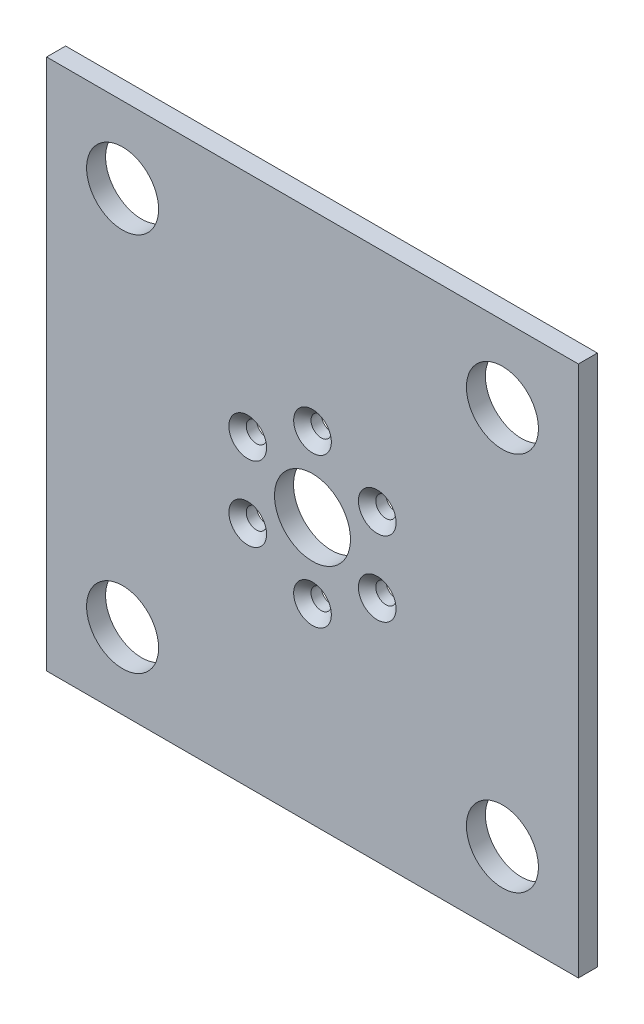
from build123d import *

# Parameters (mm, degrees)
SKETCH1_W                                       = 88.9
SKETCH1_H                                       = 88.9
BOSS_EXTRUDE1_DEPTH                             = 3.175
SKETCH3_R                                       = 6.018919743
CUT_EXTRUDE1_DEPTH                              = 4.175
MIRROR2_COPY_1_SKETCH_R                         = 6.018919743
MIRROR2_COPY_1_DEPTH                            = 4.175
SKETCH4_R                                       = 6.35
CUT_EXTRUDE2_DEPTH                              = 4.175
CSK_FOR_M3_FLAT_HEAD_MACHINE_SCREW1_D           = 3.4
CSK_FOR_M3_FLAT_HEAD_MACHINE_SCREW1_CSINK_D     = 6.3
CSK_FOR_M3_FLAT_HEAD_MACHINE_SCREW1_CSINK_ANGLE = 90
CIRPATTERN1_COUNT                               = 6


with BuildPart() as part:
    # Sketch1 → Boss-Extrude1 (new body)
    with BuildSketch(Plane.XY):
        Rectangle(SKETCH1_W, SKETCH1_H)
    extrude(amount=BOSS_EXTRUDE1_DEPTH)

    # Sketch3 → Cut-Extrude1 (cut, through all)
    with BuildSketch(Plane.XY.offset(3.175)):
        with Locations((-31.75, 31.75)):
            Circle(SKETCH3_R)
    cut_extrude1 = extrude(amount=-CUT_EXTRUDE1_DEPTH, mode=Mode.SUBTRACT)

    # Mirror1: Cut-Extrude1 across plane
    add(cut_extrude1.mirror(Plane(origin=(0, 0, 0), x_dir=(0, 0, 1), z_dir=(1, 0, 0))), mode=Mode.SUBTRACT)

    # Mirror2: Cut-Extrude1 across plane
    add(cut_extrude1.mirror(Plane.ZX), mode=Mode.SUBTRACT)

    # Mirror2 copy 1 sketch → Mirror2 copy 1 (cut, through all)
    with BuildSketch(Plane(origin=(0, 0, 3.175), x_dir=(-1, 0, 0), z_dir=(0, 0, 1))):
        with Locations((-31.75, 31.75)):
            Circle(MIRROR2_COPY_1_SKETCH_R)
    extrude(amount=-MIRROR2_COPY_1_DEPTH, mode=Mode.SUBTRACT)

    # Sketch4 → Cut-Extrude2 (cut, through all)
    with BuildSketch(Plane.XY.offset(3.175)):
        Circle(SKETCH4_R)
    extrude(amount=-CUT_EXTRUDE2_DEPTH, mode=Mode.SUBTRACT)

    # CSK for M3 Flat Head Machine Screw1 (through all)
    with Locations(Plane.XY.offset(3.175)):
        with Locations((0, 12.5)):
            csk_for_m3_flat_head_machine_screw1 = CounterSinkHole(CSK_FOR_M3_FLAT_HEAD_MACHINE_SCREW1_D / 2, CSK_FOR_M3_FLAT_HEAD_MACHINE_SCREW1_CSINK_D / 2, counter_sink_angle=CSK_FOR_M3_FLAT_HEAD_MACHINE_SCREW1_CSINK_ANGLE)

    # CirPattern1: CSK for M3 Flat Head Machine Screw1 ×6 about axis
    cirpattern1_axis = Axis((0, 0, 0), (0, 0, 1))
    for i in range(1, CIRPATTERN1_COUNT):
        add(csk_for_m3_flat_head_machine_screw1.rotate(cirpattern1_axis, i * 360 / CIRPATTERN1_COUNT), mode=Mode.SUBTRACT)


solid = part.part
